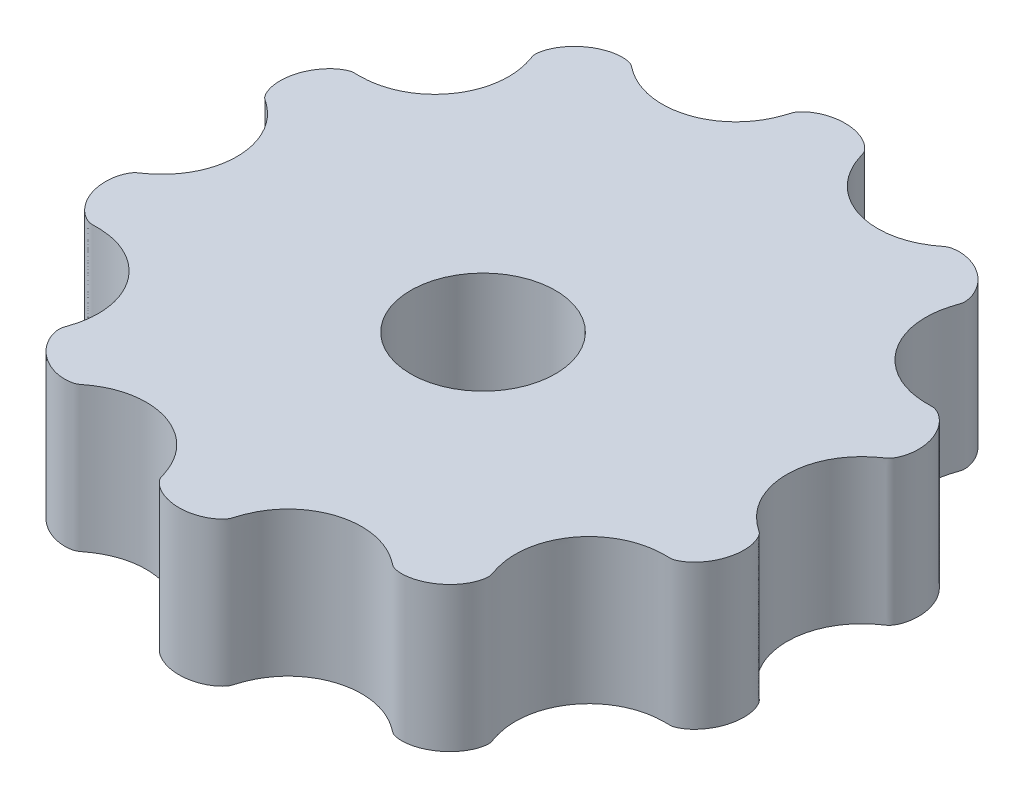
from build123d import *

# Parameters (mm, degrees)
BOSS_EXTRUDE1_DEPTH = 5
SKETCH3_R           = 2.5
CUT_EXTRUDE1_DEPTH  = 6.0000001


with BuildPart() as part:
    # Sketch2 → Boss-Extrude1 (new body)
    with BuildSketch(Plane(origin=(0, 0, 0), x_dir=(1, 0, 0), z_dir=(0, 1, 0))):
        with BuildLine():
            add(Edge.make_bspline(
                [(9.500000325, 0), (9.500000325, 0.022522001), (9.500692059, 0.067774304), (9.503804849, 0.162087858), (9.512098409, 0.2516934), (9.524520896, 0.360480596), (9.54105054, 0.458237903), (9.566811347, 0.585726672), (9.606464232, 0.73614829), (9.665451408, 0.912119982), (9.750023159, 1.10745952), (9.852003354, 1.297898688), (9.96942695, 1.478532055), (10.101308221, 1.648816831), (10.228374329, 1.787580708), (10.344769266, 1.898879013), (10.44633753, 1.986464548), (10.519666369, 2.045118388), (10.583817952, 2.093676689), (10.641009041, 2.134933423), (10.689840736, 2.170606656), (10.743690877, 2.205452597), (10.795072079, 2.249594085), (10.840329669, 2.31101941), (10.884115842, 2.382698733), (10.934320577, 2.489446735), (11.000187296, 2.687574001), (11.040659814, 2.977751964), (11.011542315, 3.355610167), (10.874318366, 3.772839791), (10.67230198, 4.094640557), (10.464381709, 4.304688129), (10.29338037, 4.422886753), (10.193590525, 4.475595802), (10.120215523, 4.504952476), (10.052812852, 4.525297074), (9.991955522, 4.530233138), (9.918834656, 4.527185285), (9.833662639, 4.527265471), (9.7361319, 4.527577991), (9.626557998, 4.532726288), (9.51719133, 4.541410263), (9.408279108, 4.554675008), (9.272897648, 4.576557863), (9.11192101, 4.611821323), (8.927217182, 4.665978375), (8.722037325, 4.745635018), (8.52428135, 4.84260879), (8.288006513, 4.984888691), (8.025247558, 5.187683062), (7.75798791, 5.464093874), (7.512948107, 5.825052884), (7.334311082, 6.218368002), (7.23849888, 6.58026054), (7.200211316, 6.89797876), (7.197551809, 7.162680183), (7.212468246, 7.372358731), (7.243680991, 7.578912793), (7.284409361, 7.75592936), (7.324421041, 7.892838771), (7.356928781, 7.991327491), (7.377401469, 8.052954756), (7.395576053, 8.10197239), (7.411237206, 8.165820773), (7.412643009, 8.269338876), (7.393553772, 8.408431306), (7.324752178, 8.632357992), (7.173966702, 8.909111786), (6.964503234, 9.151800316), (6.709043822, 9.350452165), (6.471093975, 9.480801247), (6.266625294, 9.561481342), (6.059293344, 9.613173504), (5.877282649, 9.632157735), (5.725017526, 9.628429466), (5.608131687, 9.610843323), (5.520281202, 9.588716348), (5.439235687, 9.554441553), (5.374183304, 9.50018588), (5.279151368, 9.43144173), (5.155609637, 9.343535031), (4.997681691, 9.246737611), (4.802909056, 9.146327835), (4.600174759, 9.062894919), (4.391197184, 8.996406151), (4.177150747, 8.94808688), (3.959715177, 8.918101391), (3.740274749, 8.90694279), (3.410411116, 8.918577874), (3.034245146, 8.986753259), (2.626597374, 9.13593016), (2.214329763, 9.387576875), (1.89470708, 9.664195792), (1.660729574, 9.946031227), (1.496559826, 10.208066528), (1.384859842, 10.435048325), (1.319762179, 10.594507834), (1.271805802, 10.73451864), (1.234659, 10.851763133), (1.208308969, 10.948956171), (1.147232068, 11.030593418), (1.080697125, 11.10535133), (1.003992964, 11.17220526), (0.923168245, 11.232556674), (0.814108463, 11.300654002), (0.674906661, 11.370136476), (0.453588876, 11.451131802), (0.186194121, 11.501305456), (-0.094387388, 11.507951406), (-0.379863078, 11.466461291), (-0.614464824, 11.397891088), (-0.822186, 11.301579404), (-0.980381539, 11.195710694), (-1.093194579, 11.09378826), (-1.163237682, 11.010277427), (-1.209201098, 10.940820994), (-1.236150739, 10.846809459), (-1.264276054, 10.758818543), (-1.293546149, 10.670305687), (-1.332365774, 10.565890873), (-1.383311247, 10.440820038), (-1.459216425, 10.280799371), (-1.568451536, 10.090577139), (-1.708406542, 9.892143786), (-1.866841444, 9.70709128), (-2.04268576, 9.537380169), (-2.28268004, 9.346510219), (-2.588159584, 9.162025391), (-2.913142141, 9.028956135), (-3.247331689, 8.948137564), (-3.520499945, 8.914693205), (-3.740274225, 8.906943819), (-3.959714446, 8.918100744), (-4.177150148, 8.948087272), (-4.391196499, 8.996405912), (-4.600174138, 9.062895067), (-4.802908375, 9.146327741), (-4.997681083, 9.246737674), (-5.155608928, 9.343535002), (-5.279150801, 9.43144173), (-5.374182529, 9.500185905), (-5.439235225, 9.554441503), (-5.520280247, 9.588716434), (-5.608131569, 9.610843168), (-5.725015828, 9.628429773), (-5.877283868, 9.632157186), (-6.059289694, 9.613174387), (-6.266628828, 9.56148011), (-6.471087481, 9.480802968), (-6.709053366, 9.350449163), (-6.964483143, 9.151806041), (-7.173996959, 8.909102684), (-7.324709532, 8.632370361), (-7.393617041, 8.40841248), (-7.412525075, 8.269373419), (-7.411410007, 8.165769688), (-7.392052145, 8.089459191), (-7.364236731, 8.016363965), (-7.328647837, 7.905111307), (-7.284053941, 7.756033848), (-7.243887139, 7.578851887), (-7.212360192, 7.372390363), (-7.197601828, 7.16266526), (-7.200180286, 6.897987707), (-7.238517797, 6.580254778), (-7.334298208, 6.218371601), (-7.512954781, 5.825050729), (-7.78902109, 5.418371284), (-8.104577343, 5.110215094), (-8.424968286, 4.891309128), (-8.722035922, 4.745635213), (-8.927217076, 4.665978266), (-9.111920007, 4.611821342), (-9.272897216, 4.576557932), (-9.408278308, 4.554674831), (-9.517190831, 4.541410679), (-9.626557163, 4.532725497), (-9.736131533, 4.527579454), (-9.833661549, 4.527262987), (-9.918834691, 4.52718927), (-9.991953859, 4.530227189), (-10.052813828, 4.525306641), (-10.120211693, 4.504933758), (-10.193595555, 4.475629242), (-10.29336926, 4.422825169), (-10.419041595, 4.336119352), (-10.555208358, 4.212843754), (-10.727993297, 4.006006075), (-10.891658584, 3.720038224), (-11.011548603, 3.355651017), (-11.040654625, 2.97772524), (-11.000189288, 2.687589559), (-10.934318487, 2.489438257), (-10.884116052, 2.382703802), (-10.84032851, 2.311016411), (-10.795071707, 2.249595731), (-10.743690016, 2.205451335), (-10.689840191, 2.170607343), (-10.641008357, 2.134933022), (-10.583817316, 2.093677308), (-10.519665711, 2.045117146), (-10.446336885, 1.986466541), (-10.344768611, 1.898875794), (-10.228373686, 1.787586182), (-10.101307562, 1.648808178), (-9.969426312, 1.478544398), (-9.852002685, 1.297878868), (-9.750022541, 1.10749487), (-9.665450704, 0.912048921), (-9.598272672, 0.71189903), (-9.554474282, 0.535729569), (-9.527625726, 0.38277173), (-9.512097815, 0.257167549), (-9.50380419, 0.154352048), (-9.500691403, 0.068636612), (-9.499999675, 0.022522001), (-9.499999675, 0), (-9.499999675, -0.022522001), (-9.500691403, -0.068636612), (-9.50380419, -0.154352048), (-9.512097815, -0.257167549), (-9.527625726, -0.38277173), (-9.554474282, -0.535729569), (-9.598272672, -0.71189903), (-9.665450704, -0.912048921), (-9.750022541, -1.10749487), (-9.852002685, -1.297878868), (-9.969426312, -1.478544398), (-10.101307562, -1.648808178), (-10.228373686, -1.787586182), (-10.344768611, -1.898875794), (-10.446336885, -1.986466541), (-10.519665711, -2.045117146), (-10.583817316, -2.093677308), (-10.641008357, -2.134933022), (-10.689840191, -2.170607343), (-10.743690016, -2.205451335), (-10.795071707, -2.249595731), (-10.84032851, -2.311016411), (-10.884116052, -2.382703802), (-10.934318487, -2.489438257), (-11.000189288, -2.687589559), (-11.040654625, -2.97772524), (-11.011548603, -3.355651017), (-10.891658584, -3.720038224), (-10.727993297, -4.006006075), (-10.555208358, -4.212843754), (-10.419041595, -4.336119352), (-10.29336926, -4.422825169), (-10.193595555, -4.475629242), (-10.120211693, -4.504933758), (-10.052813828, -4.525306641), (-9.991953859, -4.530227189), (-9.918834691, -4.52718927), (-9.833661549, -4.527262987), (-9.736131533, -4.527579454), (-9.626557163, -4.532725497), (-9.517190831, -4.541410679), (-9.408278308, -4.554674831), (-9.272897216, -4.576557932), (-9.111920007, -4.611821342), (-8.927217076, -4.665978266), (-8.722035922, -4.745635213), (-8.424968286, -4.891309128), (-8.104577343, -5.110215094), (-7.78902109, -5.418371284), (-7.512954781, -5.825050729), (-7.334298208, -6.218371601), (-7.238517797, -6.580254778), (-7.200180286, -6.897987707), (-7.197601828, -7.16266526), (-7.212360192, -7.372390363), (-7.243887139, -7.578851887), (-7.284053941, -7.756033848), (-7.328647837, -7.905111307), (-7.364236731, -8.016363965), (-7.392052145, -8.089459191), (-7.411410007, -8.165769688), (-7.412525075, -8.269373419), (-7.393617041, -8.40841248), (-7.324709532, -8.632370361), (-7.173996959, -8.909102684), (-6.964483143, -9.151806041), (-6.709053366, -9.350449163), (-6.471087481, -9.480802968), (-6.266628828, -9.56148011), (-6.059289694, -9.613174387), (-5.877283868, -9.632157186), (-5.725015828, -9.628429773), (-5.608131569, -9.610843168), (-5.520280247, -9.588716434), (-5.439235225, -9.554441503), (-5.374182529, -9.500185905), (-5.279150801, -9.43144173), (-5.155608928, -9.343535002), (-4.997681083, -9.246737674), (-4.802908375, -9.146327741), (-4.600174138, -9.062895067), (-4.391196499, -8.996405912), (-4.177150148, -8.948087272), (-3.959714446, -8.918100744), (-3.740274225, -8.906943819), (-3.520499945, -8.914693205), (-3.247331689, -8.948137564), (-2.913142141, -9.028956135), (-2.588159584, -9.162025391), (-2.28268004, -9.346510219), (-2.04268576, -9.537380169), (-1.866841444, -9.70709128), (-1.708406542, -9.892143786), (-1.568451536, -10.090577139), (-1.459216425, -10.280799371), (-1.383311247, -10.440820038), (-1.332365774, -10.565890873), (-1.293546149, -10.670305687), (-1.264276054, -10.758818543), (-1.236150739, -10.846809459), (-1.209201098, -10.940820994), (-1.163237682, -11.010277427), (-1.093194579, -11.09378826), (-0.980381539, -11.195710694), (-0.822186, -11.301579404), (-0.614464824, -11.397891088), (-0.379863078, -11.466461291), (-0.094387388, -11.507951406), (0.186194121, -11.501305456), (0.453588876, -11.451131802), (0.674906661, -11.370136476), (0.814108463, -11.300654002), (0.923168245, -11.232556674), (1.003992964, -11.17220526), (1.080697125, -11.10535133), (1.147232068, -11.030593418), (1.208308969, -10.948956171), (1.234659, -10.851763133), (1.271805802, -10.73451864), (1.319762179, -10.594507834), (1.384859842, -10.435048325), (1.496559826, -10.208066528), (1.660729574, -9.946031227), (1.89470708, -9.664195792), (2.214329763, -9.387576875), (2.626597374, -9.13593016), (3.034245146, -8.986753259), (3.410411116, -8.918577874), (3.740274749, -8.90694279), (3.959715177, -8.918101391), (4.177150747, -8.94808688), (4.391197184, -8.996406151), (4.600174759, -9.062894919), (4.802909056, -9.146327835), (4.997681691, -9.246737611), (5.155609637, -9.343535031), (5.279151368, -9.43144173), (5.374183304, -9.50018588), (5.439235687, -9.554441553), (5.520281202, -9.588716348), (5.608131687, -9.610843323), (5.725017526, -9.628429466), (5.877282649, -9.632157735), (6.059293344, -9.613173504), (6.266625294, -9.561481342), (6.471093975, -9.480801247), (6.709043822, -9.350452165), (6.964503234, -9.151800316), (7.173966702, -8.909111786), (7.324752178, -8.632357992), (7.393553772, -8.408431306), (7.412643009, -8.269338876), (7.411237206, -8.165820773), (7.395576053, -8.10197239), (7.377401469, -8.052954756), (7.356928781, -7.991327491), (7.324421041, -7.892838771), (7.284409361, -7.75592936), (7.243680991, -7.578912793), (7.212468246, -7.372358731), (7.197551809, -7.162680183), (7.200211316, -6.89797876), (7.23849888, -6.58026054), (7.334311082, -6.218368002), (7.512948107, -5.825052884), (7.75798791, -5.464093874), (8.025247558, -5.187683062), (8.288006513, -4.984888691), (8.52428135, -4.84260879), (8.722037325, -4.745635018), (8.927217182, -4.665978375), (9.11192101, -4.611821323), (9.272897648, -4.576557863), (9.408279108, -4.554675008), (9.51719133, -4.541410263), (9.626557998, -4.532726288), (9.7361319, -4.527577991), (9.833662639, -4.527265471), (9.918834656, -4.527185285), (9.991955522, -4.530233138), (10.052812852, -4.525297074), (10.120215523, -4.504952476), (10.193590525, -4.475595802), (10.29338037, -4.422886753), (10.464381709, -4.304688129), (10.67230198, -4.094640557), (10.874318366, -3.772839791), (11.011542315, -3.355610167), (11.040659814, -2.977751964), (11.000187296, -2.687574001), (10.934320577, -2.489446735), (10.884115842, -2.382698733), (10.840329669, -2.31101941), (10.795072079, -2.249594085), (10.743690877, -2.205452597), (10.689840736, -2.170606656), (10.641009041, -2.134933423), (10.583817952, -2.093676689), (10.519666369, -2.045118388), (10.44633753, -1.986464548), (10.344769266, -1.898879013), (10.228374329, -1.787580708), (10.101308221, -1.648816831), (9.96942695, -1.478532055), (9.852003354, -1.297898688), (9.750023159, -1.10745952), (9.665451408, -0.912119982), (9.606464232, -0.73614829), (9.566811347, -0.585726672), (9.54105054, -0.458237903), (9.524520896, -0.360480596), (9.512098409, -0.2516934), (9.503804849, -0.162087858), (9.500692059, -0.067774304), (9.500000325, -0.022522001), (9.500000325, 0)],
                knots=[0, 0, 0, 0, 0, 0.001260331, 0.002520662, 0.003780994, 0.005041325, 0.006301656, 0.007561987, 0.01008265, 0.012730261, 0.015377873, 0.018025485, 0.020673097, 0.023308402, 0.025943706, 0.027261358, 0.028579011, 0.029896663, 0.030555489, 0.031214315, 0.032042454, 0.032870592, 0.033698731, 0.034526869, 0.035764524, 0.037002179, 0.039477488, 0.044759044, 0.050038774, 0.055442712, 0.060846034, 0.063237566, 0.064433332, 0.065629098, 0.06637622, 0.067123343, 0.067870465, 0.068617588, 0.069964754, 0.071311921, 0.072659087, 0.074006254, 0.07535342, 0.076700586, 0.079394919, 0.082096812, 0.084798705, 0.087500598, 0.09020249, 0.095630127, 0.101057763, 0.106294779, 0.111531794, 0.11675343, 0.119364247, 0.121975065, 0.124522384, 0.127069704, 0.129617023, 0.130890683, 0.131527513, 0.132164343, 0.132809474, 0.133454605, 0.134744867, 0.137215779, 0.13968669, 0.14490202, 0.150116357, 0.152809494, 0.155502631, 0.15819549, 0.160888348, 0.163272161, 0.164464068, 0.165655974, 0.166686332, 0.167716691, 0.168747049, 0.169777407, 0.172465672, 0.175153937, 0.177842202, 0.180530467, 0.18322322, 0.185915972, 0.188608725, 0.191301478, 0.194004182, 0.202112294, 0.207288287, 0.212464281, 0.217624882, 0.222785483, 0.225203352, 0.227621222, 0.230039091, 0.231248026, 0.232456961, 0.233691078, 0.234925195, 0.236167212, 0.237409229, 0.238651246, 0.239893262, 0.242468429, 0.245043596, 0.250193925, 0.253186389, 0.256178853, 0.259170844, 0.262162835, 0.264384997, 0.265496078, 0.26660716, 0.267520199, 0.268433238, 0.270259316, 0.271172355, 0.272085395, 0.273911473, 0.276889658, 0.279867843, 0.282846028, 0.285824213, 0.288840087, 0.29185596, 0.297887706, 0.303293114, 0.305995818, 0.308698522, 0.311391275, 0.314084028, 0.31677678, 0.319469533, 0.322157798, 0.324846063, 0.327534328, 0.330222593, 0.331252951, 0.332283309, 0.333313668, 0.334344026, 0.335535932, 0.336727839, 0.339111652, 0.34180451, 0.344497369, 0.347190506, 0.349883643, 0.35509798, 0.36031331, 0.362784221, 0.365255133, 0.366545395, 0.367190526, 0.367835657, 0.369109317, 0.370382977, 0.372930296, 0.375477616, 0.378024935, 0.380635753, 0.38324657, 0.388468206, 0.393705221, 0.398942237, 0.404369873, 0.412499402, 0.415201295, 0.417903188, 0.420605081, 0.423299414, 0.42464658, 0.425993746, 0.427340913, 0.428688079, 0.430035246, 0.431382412, 0.432129535, 0.432876657, 0.43362378, 0.434370902, 0.435566668, 0.436762434, 0.439153966, 0.441855627, 0.444557288, 0.449961226, 0.455240956, 0.460522512, 0.462997821, 0.464235476, 0.465473131, 0.466301269, 0.467129408, 0.467957546, 0.468785685, 0.469444511, 0.470103337, 0.471420989, 0.472738642, 0.474056294, 0.476691598, 0.479326903, 0.481974515, 0.484622127, 0.487269739, 0.48991735, 0.492438013, 0.494958675, 0.496219006, 0.497479338, 0.498739669, 0.5, 0.5, 0.5, 0.5, 0.501260331, 0.502520662, 0.503780994, 0.505041325, 0.507561987, 0.51008265, 0.512730261, 0.515377873, 0.518025485, 0.520673097, 0.523308402, 0.525943706, 0.527261358, 0.528579011, 0.529896663, 0.530555489, 0.531214315, 0.532042454, 0.532870592, 0.533698731, 0.534526869, 0.535764524, 0.537002179, 0.539477488, 0.544759044, 0.550038774, 0.555442712, 0.558144373, 0.560846034, 0.563237566, 0.564433332, 0.565629098, 0.56637622, 0.567123343, 0.567870465, 0.568617588, 0.569964754, 0.571311921, 0.572659087, 0.574006254, 0.57535342, 0.576700586, 0.579394919, 0.582096812, 0.584798705, 0.587500598, 0.595630127, 0.601057763, 0.606294779, 0.611531794, 0.61675343, 0.619364247, 0.621975065, 0.624522384, 0.627069704, 0.629617023, 0.630890683, 0.632164343, 0.632809474, 0.633454605, 0.634744867, 0.637215779, 0.63968669, 0.64490202, 0.650116357, 0.652809494, 0.655502631, 0.65819549, 0.660888348, 0.663272161, 0.664464068, 0.665655974, 0.666686332, 0.667716691, 0.668747049, 0.669777407, 0.672465672, 0.675153937, 0.677842202, 0.680530467, 0.68322322, 0.685915972, 0.688608725, 0.691301478, 0.694004182, 0.696706886, 0.702112294, 0.70814404, 0.711159913, 0.714175787, 0.717153972, 0.720132157, 0.723110342, 0.726088527, 0.727914605, 0.728827645, 0.729740684, 0.731566762, 0.732479801, 0.73339284, 0.734503922, 0.735615003, 0.737837165, 0.740829156, 0.743821147, 0.746813611, 0.749806075, 0.754956404, 0.757531571, 0.760106738, 0.761348754, 0.762590771, 0.763832788, 0.765074805, 0.766308922, 0.767543039, 0.768751974, 0.769960909, 0.772378778, 0.774796648, 0.777214517, 0.782375118, 0.787535719, 0.792711713, 0.797887706, 0.805995818, 0.808698522, 0.811391275, 0.814084028, 0.81677678, 0.819469533, 0.822157798, 0.824846063, 0.827534328, 0.830222593, 0.831252951, 0.832283309, 0.833313668, 0.834344026, 0.835535932, 0.836727839, 0.839111652, 0.84180451, 0.844497369, 0.847190506, 0.849883643, 0.85509798, 0.86031331, 0.862784221, 0.865255133, 0.866545395, 0.867190526, 0.867835657, 0.868472487, 0.869109317, 0.870382977, 0.872930296, 0.875477616, 0.878024935, 0.880635753, 0.88324657, 0.888468206, 0.893705221, 0.898942237, 0.904369873, 0.90979751, 0.912499402, 0.915201295, 0.917903188, 0.920605081, 0.923299414, 0.92464658, 0.925993746, 0.927340913, 0.928688079, 0.930035246, 0.931382412, 0.932129535, 0.932876657, 0.93362378, 0.934370902, 0.935566668, 0.936762434, 0.939153966, 0.944557288, 0.949961226, 0.955240956, 0.960522512, 0.962997821, 0.964235476, 0.965473131, 0.966301269, 0.967129408, 0.967957546, 0.968785685, 0.969444511, 0.970103337, 0.971420989, 0.972738642, 0.974056294, 0.976691598, 0.979326903, 0.981974515, 0.984622127, 0.987269739, 0.98991735, 0.992438013, 0.993698344, 0.994958675, 0.996219006, 0.997479338, 0.998739669, 1, 1, 1, 1, 1], degree=4))
        make_face()
    extrude(amount=BOSS_EXTRUDE1_DEPTH)

    # Sketch3 → Cut-Extrude1 (cut, through all)
    with BuildSketch(Plane(origin=(0, 5, 0), x_dir=(1, 0, 0), z_dir=(0, 1, 0))):
        with Locations((0, -1)):
            Circle(SKETCH3_R)
    extrude(amount=-CUT_EXTRUDE1_DEPTH, mode=Mode.SUBTRACT)


solid = part.part
